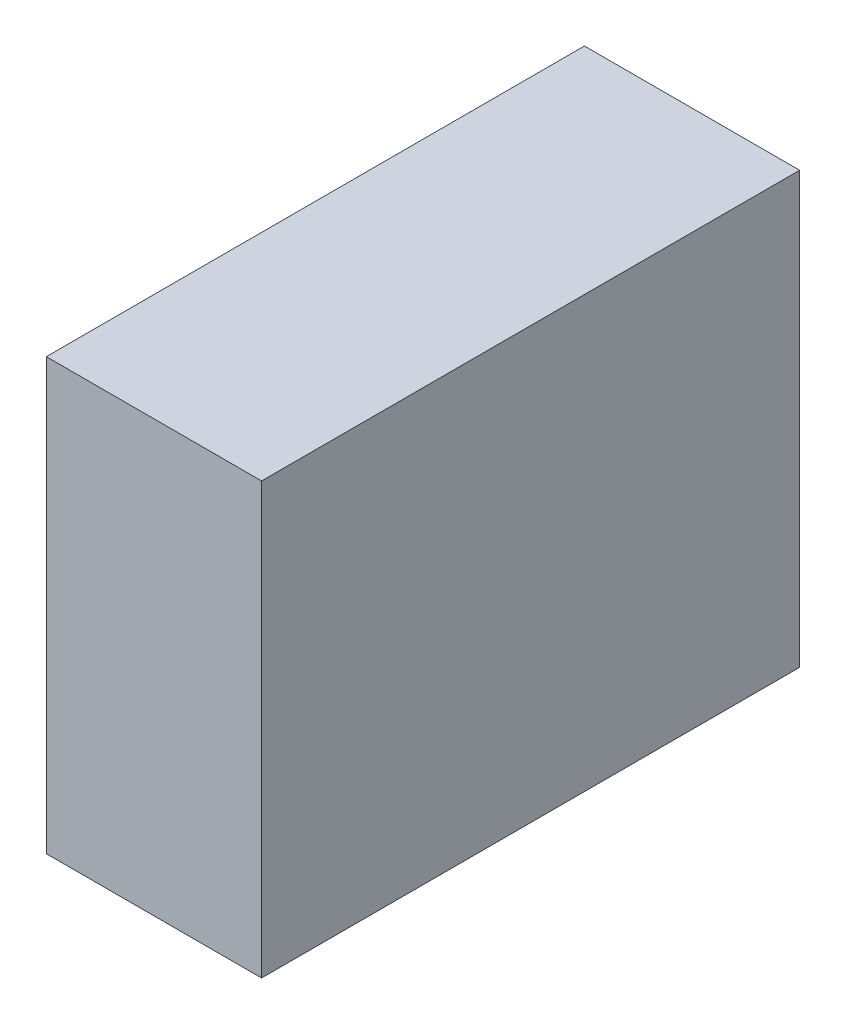
from build123d import *

# Parameters (mm, degrees)
SKETCH1_W      = 20
SKETCH1_H      = 40
EXTRUDE1_DEPTH = 50


with BuildPart() as part:
    # Sketch1 → Extrude1 (new body)
    with BuildSketch(Plane.XY):
        with Locations((10, -20)):
            Rectangle(SKETCH1_W, SKETCH1_H)
    extrude(amount=EXTRUDE1_DEPTH)


solid = part.part
